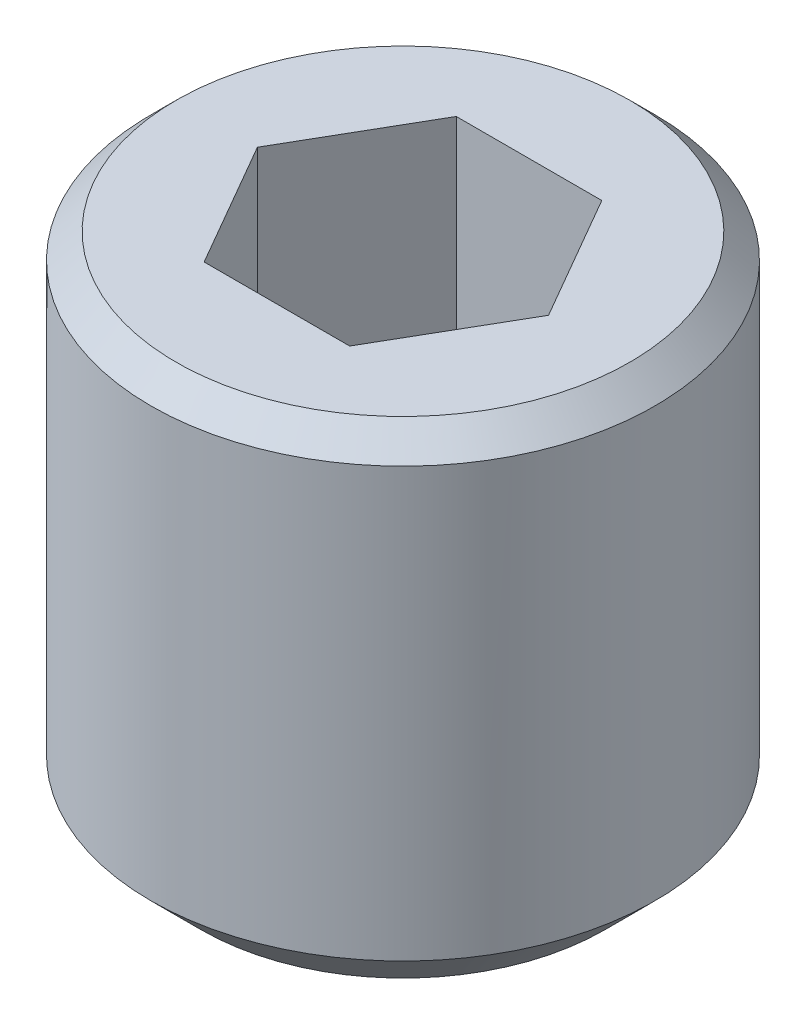
from build123d import *

# Parameters (mm, degrees)
CROQUIS1_W            = 1.5
CROQUIS1_H            = 3
CORTAR_EXTRUIR2_DEPTH = 1.5
CHAFL_N3_SIZE         = 0.3
CHAFL_N4_SIZE         = 0.15


with BuildPart() as part:
    # Croquis1 → Revolución1 (revolve)
    with BuildSketch(Plane.XY):
        with Locations((0.75, -1.5)):
            Rectangle(CROQUIS1_W, CROQUIS1_H)
    revolve(axis=Axis((0, 0, 0), (0, -1, 0)))

    # Croquis3 → Cortar-Extruir2 (cut)
    with BuildSketch(Plane(origin=(0, 0, 0), x_dir=(1, 0, 0), z_dir=(0, 1, 0))):
        Polygon((-0.433012702, 0.75), (-0.866025404, 0), (-0.433012702, -0.75), (0.433012702, -0.75), (0.866025404, 0), (0.433012702, 0.75), align=None)
    extrude(amount=-CORTAR_EXTRUIR2_DEPTH, mode=Mode.SUBTRACT)

    # Chaflán3
    chafl_n3_edges = [part.edges().sort_by_distance(p)[0] for p in [
        (-1.5, -3, 0),
    ]]
    chamfer(chafl_n3_edges, length=CHAFL_N3_SIZE)

    # Chaflán4
    chafl_n4_edges = [part.edges().sort_by_distance(p)[0] for p in [
        (-1.5, 0, 0),
    ]]
    chamfer(chafl_n4_edges, length=CHAFL_N4_SIZE)


solid = part.part
